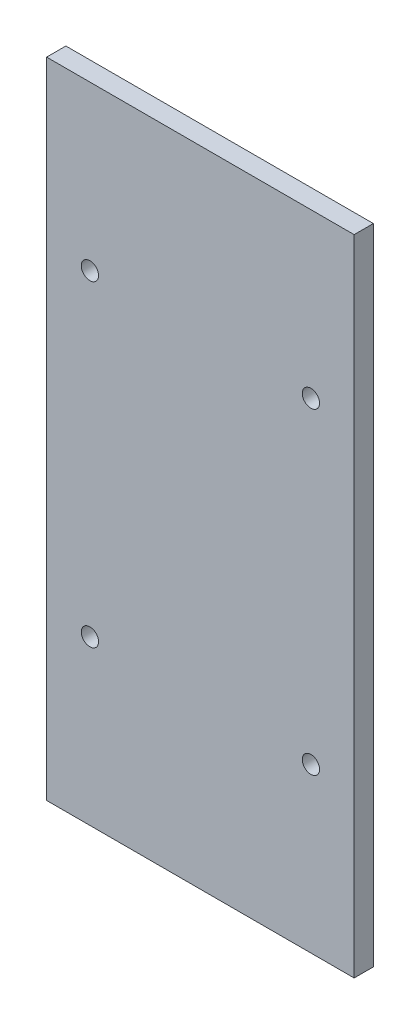
from build123d import *

# Parameters (mm, degrees)
SKETCH1_W           = 320
SKETCH1_H           = 670
BOSS_EXTRUDE1_DEPTH = 20
SKETCH2_R           = 9
CUT_EXTRUDE1_DEPTH  = 21


with BuildPart() as part:
    # Sketch1 → Boss-Extrude1 (new body)
    with BuildSketch(Plane.XY):
        with Locations((100, -275)):
            Rectangle(SKETCH1_W, SKETCH1_H)
    extrude(amount=BOSS_EXTRUDE1_DEPTH)

    # Sketch2 → Cut-Extrude1 (cut, through all)
    with BuildSketch(Plane.XY.offset(20)):
        with Locations((215, -440)):
            Circle(SKETCH2_R)
        with Locations((-15, -440)):
            Circle(SKETCH2_R)
        with Locations((-15, -110)):
            Circle(SKETCH2_R)
        with Locations((215, -110)):
            Circle(SKETCH2_R)
    extrude(amount=-CUT_EXTRUDE1_DEPTH, mode=Mode.SUBTRACT)


solid = part.part
